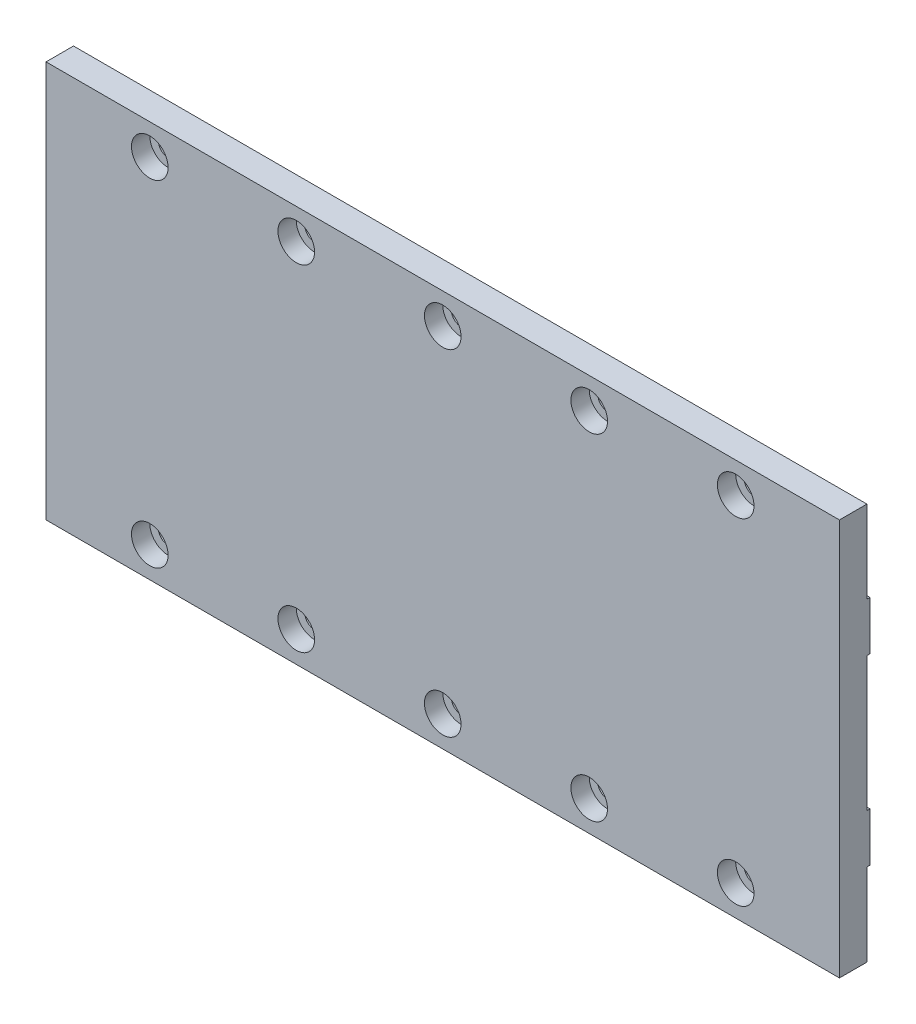
from build123d import *

# Parameters (mm, degrees)
ESQUISSE1_W             = 130
ESQUISSE1_H             = 65
ESQUISSE1_R             = 1.6
BOSS_EXTRU_1_DEPTH      = 5
ESQUISSE2_W             = 130
ESQUISSE2_H             = 13.5
ESQUISSE2_H_2           = 22
ENL_V_MAT_EXTRU_1_DEPTH = 0.5
ESQUISSE3_R             = 3
ENL_V_MAT_EXTRU_2_DEPTH = 3


with BuildPart() as part:
    # Esquisse1 → Boss.-Extru.1 (new body)
    with BuildSketch(Plane.XY):
        with Locations((65, 32.5)):
            Rectangle(ESQUISSE1_W, ESQUISSE1_H)
        with Locations((113, 5)):
            Circle(ESQUISSE1_R, mode=Mode.SUBTRACT)
        with Locations((89, 5)):
            Circle(ESQUISSE1_R, mode=Mode.SUBTRACT)
        with Locations((65, 5)):
            Circle(ESQUISSE1_R, mode=Mode.SUBTRACT)
        with Locations((41, 5)):
            Circle(ESQUISSE1_R, mode=Mode.SUBTRACT)
        with Locations((17, 5)):
            Circle(ESQUISSE1_R, mode=Mode.SUBTRACT)
        with Locations((113, 60)):
            Circle(ESQUISSE1_R, mode=Mode.SUBTRACT)
        with Locations((89, 60)):
            Circle(ESQUISSE1_R, mode=Mode.SUBTRACT)
        with Locations((65, 60)):
            Circle(ESQUISSE1_R, mode=Mode.SUBTRACT)
        with Locations((41, 60)):
            Circle(ESQUISSE1_R, mode=Mode.SUBTRACT)
        with Locations((17, 60)):
            Circle(ESQUISSE1_R, mode=Mode.SUBTRACT)
    extrude(amount=BOSS_EXTRU_1_DEPTH)

    # Esquisse2 → Enlèv. mat.-Extru.1 (cut)
    with BuildSketch(Plane(origin=(0, 0, 0), x_dir=(-1, 0, 0), z_dir=(0, 0, -1))):
        with Locations((-65, 58.25)):
            Rectangle(ESQUISSE2_W, ESQUISSE2_H)
        with Locations((-65, 6.75)):
            Rectangle(ESQUISSE2_W, ESQUISSE2_H)
        with Locations((-65, 32.5)):
            Rectangle(ESQUISSE2_W, ESQUISSE2_H_2)
    extrude(amount=-ENL_V_MAT_EXTRU_1_DEPTH, mode=Mode.SUBTRACT)

    # Esquisse3 → Enlèv. mat.-Extru.2 (cut)
    with BuildSketch(Plane.XY.offset(5)):
        with Locations((17, 60)):
            Circle(ESQUISSE3_R)
        with Locations((41, 60)):
            Circle(ESQUISSE3_R)
        with Locations((65, 60)):
            Circle(ESQUISSE3_R)
        with Locations((89, 60)):
            Circle(ESQUISSE3_R)
        with Locations((113, 60)):
            Circle(ESQUISSE3_R)
        with Locations((113, 5)):
            Circle(ESQUISSE3_R)
        with Locations((89, 5)):
            Circle(ESQUISSE3_R)
        with Locations((65, 5)):
            Circle(ESQUISSE3_R)
        with Locations((41, 5)):
            Circle(ESQUISSE3_R)
        with Locations((17, 5)):
            Circle(ESQUISSE3_R)
    extrude(amount=-ENL_V_MAT_EXTRU_2_DEPTH, mode=Mode.SUBTRACT)


solid = part.part
